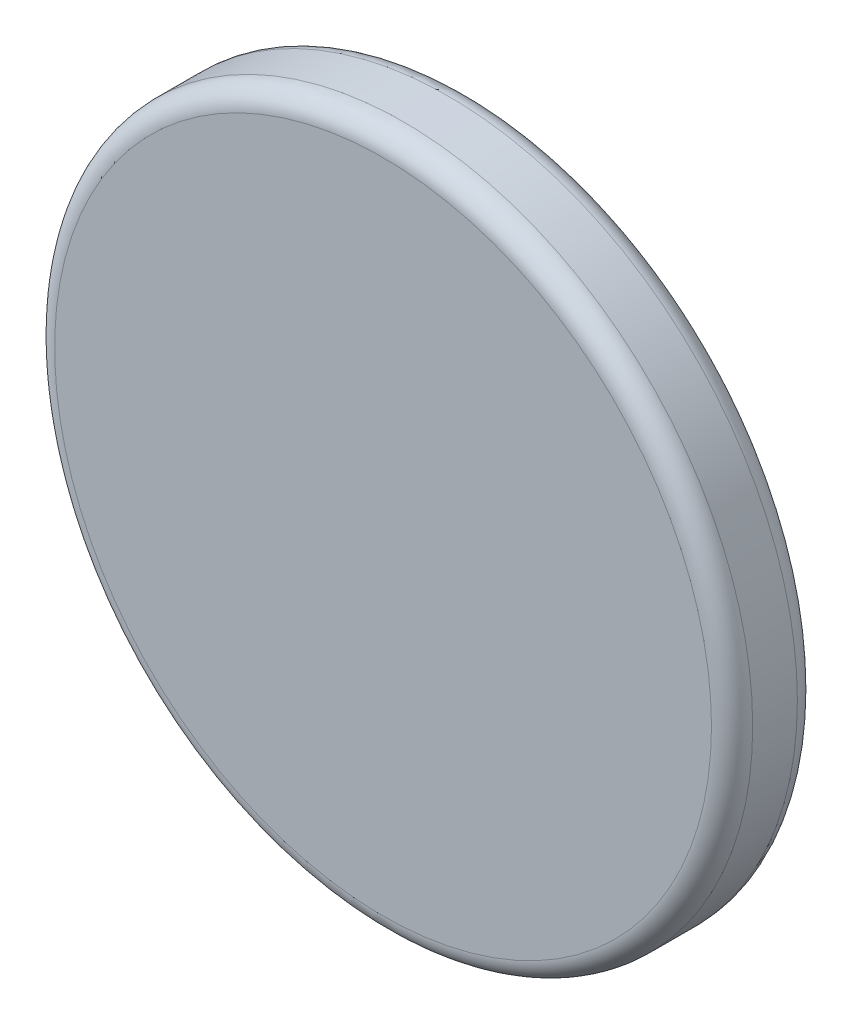
from build123d import *

# Parameters (mm, degrees)
SKETCH1_R           = 203.2
BOSS_EXTRUDE1_DEPTH = 25
FILLET1_R           = 12


with BuildPart() as part:
    # Sketch1 → Boss-Extrude1 (new body, symmetric)
    with BuildSketch(Plane.XY):
        Circle(SKETCH1_R)
    extrude(amount=BOSS_EXTRUDE1_DEPTH, both=True)

    # Fillet1
    fillet1_edges = [part.edges().sort_by_distance(p)[0] for p in [
        (-203.2, 0, -25),
        (-203.2, 0, 25),
    ]]
    fillet(fillet1_edges, radius=FILLET1_R)


solid = part.part
